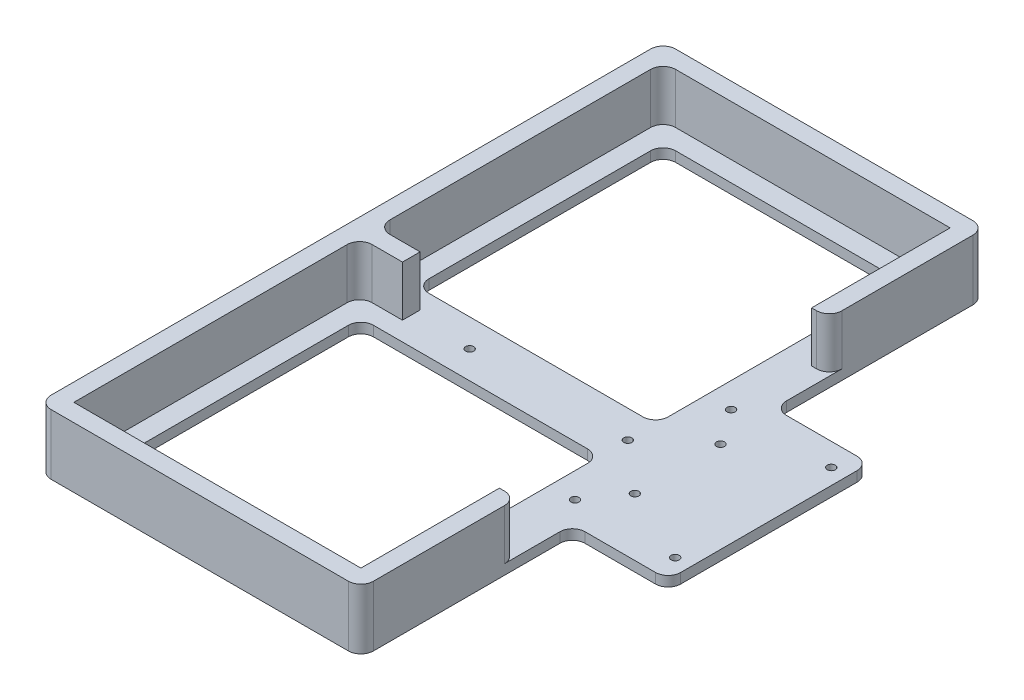
from build123d import *

# Parameters (mm, degrees)
SKETCH1_R           = 1.6
BOSS_EXTRUDE1_DEPTH = 2
BOSS_EXTRUDE2_DEPTH = 20
FILLET1_R           = 5


with BuildPart() as part:
    # Sketch1 → Boss-Extrude1 (new body, symmetric)
    with BuildSketch(Plane(origin=(0, 0, 0), x_dir=(1, 0, 0), z_dir=(0, 1, 0))):
        Polygon((18, 40), (56, 40), (56, -40), (18, -40), (18, -124), (-110, -124), (-110, -22.904637916), (-110, 22.904637916), (-110, 124), (18, 124), align=None)
        Circle(SKETCH1_R, mode=Mode.SUBTRACT)
        with Locations((-62.8, 0)):
            Circle(SKETCH1_R, mode=Mode.SUBTRACT)
        with Locations((10, 31)):
            Circle(SKETCH1_R, mode=Mode.SUBTRACT)
        with Locations((49.8, 31)):
            Circle(SKETCH1_R, mode=Mode.SUBTRACT)
        with Locations((49.8, -31)):
            Circle(SKETCH1_R, mode=Mode.SUBTRACT)
        with Locations((10, -31)):
            Circle(SKETCH1_R, mode=Mode.SUBTRACT)
        with Locations((19.8, 17)):
            Circle(SKETCH1_R, mode=Mode.SUBTRACT)
        with Locations((19.8, -17)):
            Circle(SKETCH1_R, mode=Mode.SUBTRACT)
        Polygon((0, 11), (-95, 11), (-95, 109), (0, 109), (0, 40), align=None, mode=Mode.SUBTRACT)
        Polygon((0, -11), (0, -40), (0, -109), (-95, -109), (-95, -11), align=None, mode=Mode.SUBTRACT)
    extrude(amount=BOSS_EXTRUDE1_DEPTH, both=True)

    # Sketch2 → Boss-Extrude2 (add)
    with BuildSketch(Plane(origin=(0, 2, 0), x_dir=(1, 0, 0), z_dir=(0, 1, 0))):
        Polygon((18, 124), (-110, 124), (-110, -124), (18, -124), (18, -117), (18, -62), (11, -62), (11, -117), (-103, -117), (-103, -3.5), (-86, -3.5), (-86, 3.5), (-103, 3.5), (-103, 117), (11, 117), (11, 62), (18, 62), (18, 117), align=None)
    extrude(amount=BOSS_EXTRUDE2_DEPTH)

    # Fillet1
    fillet1_edges = [part.edges().sort_by_distance(p)[0] for p in [
        (18, 12, 62),
        (-103, 12, 3.5),
        (-103, 12, -3.5),
        (-103, 12, -117),
        (18, 12, -62),
        (18, 0, 40),
        (18, 10, 124),
        (-110, 10, 124),
        (-110, 10, -124),
        (18, 10, -124),
        (18, 0, -40),
        (56, 0, -40),
        (56, 0, 40),
        (0, 0, -11),
        (0, 0, -109),
        (-95, 0, -109),
        (-95, 0, -11),
        (0, 0, 11),
        (-95, 0, 11),
        (-95, 0, 109),
        (0, 0, 109),
    ]]
    fillet(fillet1_edges, radius=FILLET1_R)


solid = part.part
